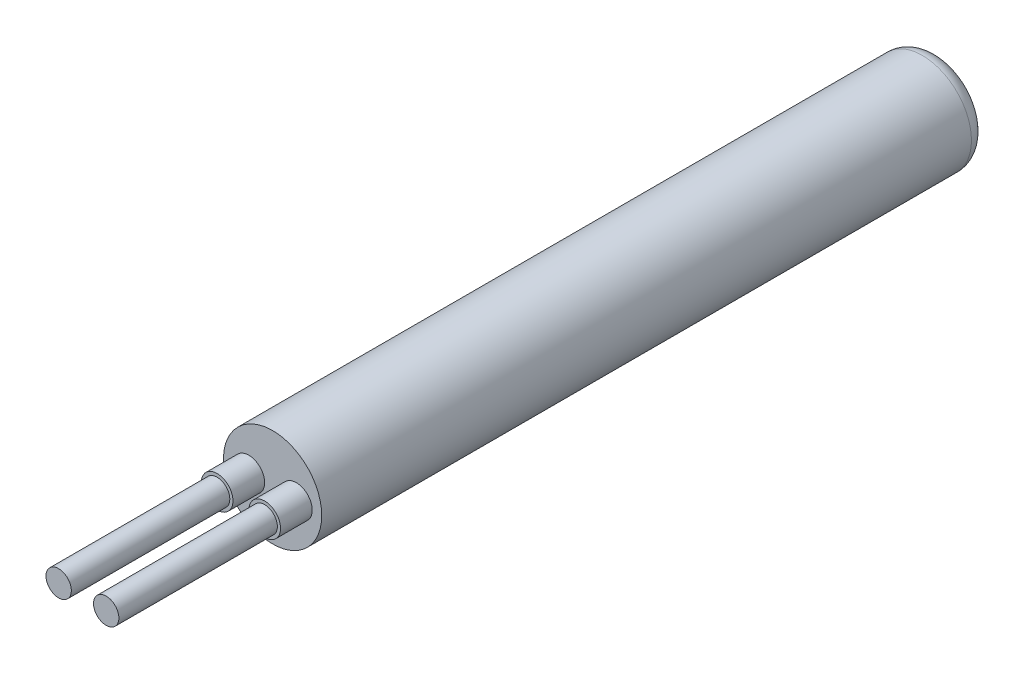
from build123d import *

# Parameters (mm, degrees)
CROQUIS1_R              = 1.55
SALIENTE_EXTRUIR1_DEPTH = 21
CROQUIS2_R              = 0.4
SALIENTE_EXTRUIR2_DEPTH = 6
CROQUIS3_R              = 0.5
CROQUIS3_R_2            = 0.4
SALIENTE_EXTRUIR3_DEPTH = 1
REDONDEO1_R             = 0.5


with BuildPart() as part:
    # Croquis1 → Saliente-Extruir1 (new body)
    with BuildSketch(Plane.XY):
        Circle(CROQUIS1_R)
    extrude(amount=SALIENTE_EXTRUIR1_DEPTH)

    # Croquis2 → Saliente-Extruir2 (add)
    with BuildSketch(Plane.XY.offset(21)):
        with Locations((0.75, 0)):
            Circle(CROQUIS2_R)
        with Locations((-0.75, 0)):
            Circle(CROQUIS2_R)
    extrude(amount=SALIENTE_EXTRUIR2_DEPTH)

    # Croquis3 → Saliente-Extruir3 (add)
    with BuildSketch(Plane.XY.offset(21)):
        with Locations((-0.75, 0)):
            Circle(CROQUIS3_R)
        with Locations((-0.75, 0)):
            Circle(CROQUIS3_R_2, mode=Mode.SUBTRACT)
        with Locations((0.75, 0)):
            Circle(CROQUIS3_R)
        with Locations((0.75, 0)):
            Circle(CROQUIS3_R_2, mode=Mode.SUBTRACT)
    extrude(amount=SALIENTE_EXTRUIR3_DEPTH)

    # Redondeo1
    redondeo1_edges = [part.edges().sort_by_distance(p)[0] for p in [
        (-1.55, 0, 0),
    ]]
    fillet(redondeo1_edges, radius=REDONDEO1_R)


solid = part.part
